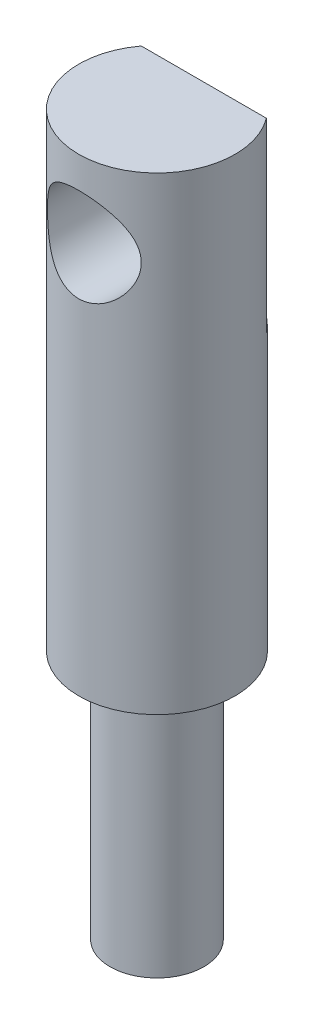
from build123d import *

# Parameters (mm, degrees)
CUT_EXTRUDE_1_DEPTH = 6
SKETCH_3_R          = 1.5
CUT_EXTRUDE_2_DEPTH = 5


with BuildPart() as part:
    # 草图1 → 旋转1 (revolve)
    with BuildSketch(Plane.XY):
        Polygon((0, 0), (2.5, 0), (2.5, -15), (1.5, -15), (1.5, -23), (0, -23), align=None)
    revolve(axis=Axis((0, 9.186035128, 0), (0, -1, 0)))

    # 草图2 → 切除-拉伸1 (cut)
    with BuildSketch(Plane(origin=(0, 0, 0), x_dir=(1, 0, 0), z_dir=(0, 1, 0))):
        with BuildLine():
            Line((-2, 1.5), (2, 1.5))
            ThreePointArc((2, 1.5), (0, 2.5), (-2, 1.5))
        make_face()
    extrude(amount=-CUT_EXTRUDE_1_DEPTH, mode=Mode.SUBTRACT)

    # 草图3 → 切除-拉伸2 (cut, through all)
    with BuildSketch(Plane(origin=(0, 0, -1.5), x_dir=(-1, 0, 0), z_dir=(0, 0, -1))):
        with Locations((0, -2.5)):
            Circle(SKETCH_3_R)
    extrude(amount=-CUT_EXTRUDE_2_DEPTH, mode=Mode.SUBTRACT)


solid = part.part
